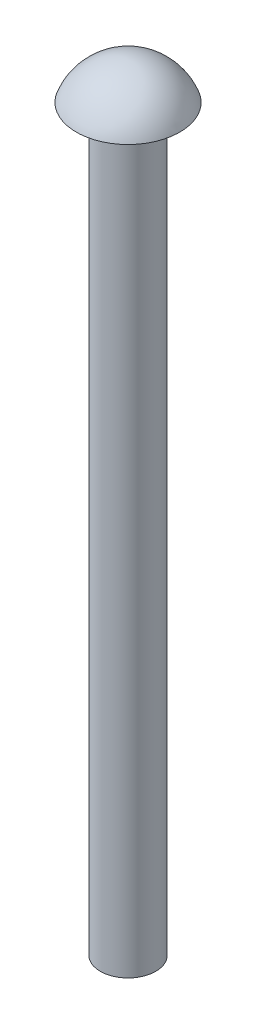
from build123d import *


with BuildPart() as part:
    # 草图1 → 旋转1 (revolve)
    with BuildSketch(Plane.XY):
        with BuildLine():
            Line((0, 0), (1.3, 0))
            Line((1.3, 0), (1.3, -40))
            Line((1.3, -40), (2.8, -40))
            Line((2.8, -40), (2.8, 2))
            ThreePointArc((2.8, 2), (1.089048757, 1.435331741), (0, 0))
        make_face()
    revolve(axis=Axis((2.8, -40, 0), (0, 1, 0)))


solid = part.part
